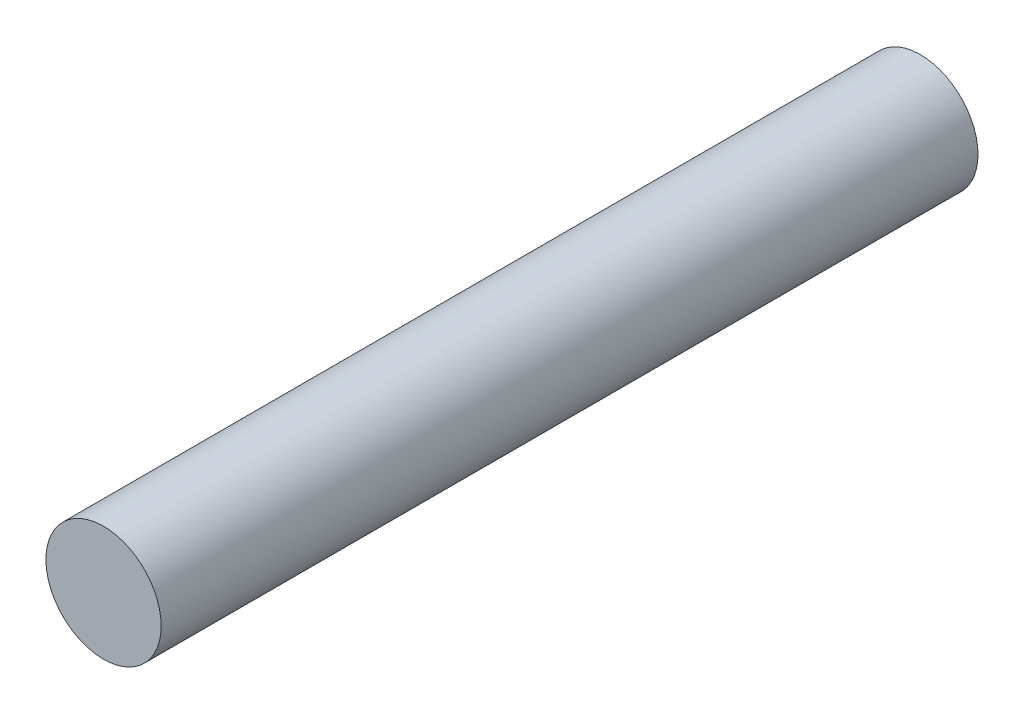
from build123d import *

# Parameters (mm, degrees)
SKETCH1_R           = 3.175
BOSS_EXTRUDE1_DEPTH = 45


with BuildPart() as part:
    # Sketch1 → Boss-Extrude1 (new body)
    with BuildSketch(Plane.XY):
        Circle(SKETCH1_R)
    extrude(amount=BOSS_EXTRUDE1_DEPTH)


solid = part.part
